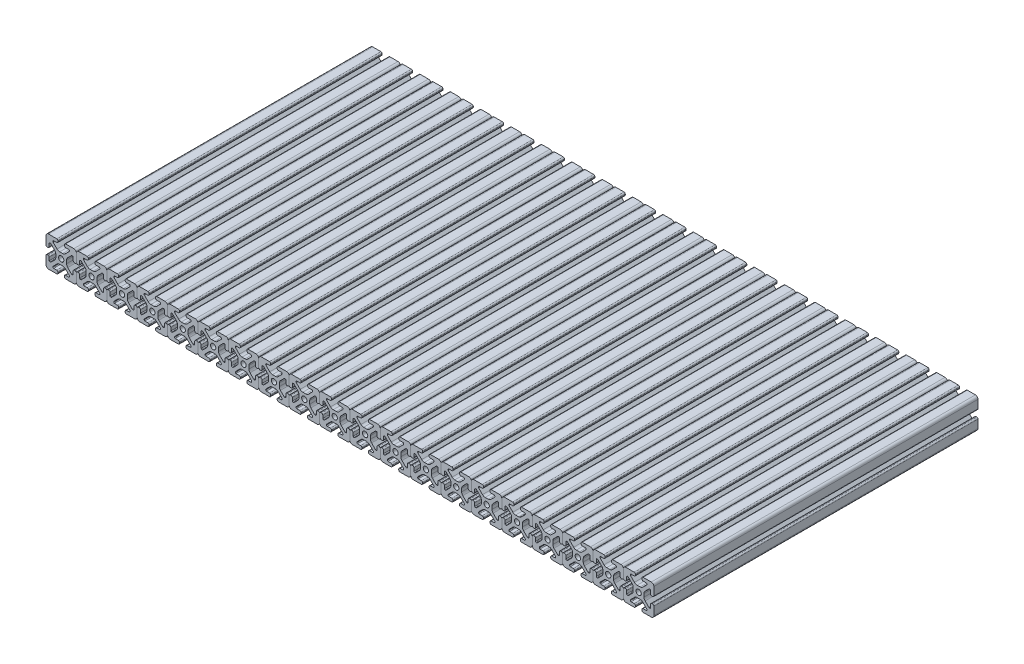
from build123d import *

# Parameters (mm, degrees)
SKETCH1_R           = 3.3274
BOSS_EXTRUDE1_DEPTH = 203.2
LPATTERN1_COUNT     = 20
LPATTERN1_PITCH     = 38.1


with BuildPart() as part:
    # Sketch1 → Boss-Extrude1 (new body, symmetric)
    with BuildSketch(Plane.XY):
        with BuildLine():
            Line((-366.014, 16.539617552), (-366.014, 17.496382454))
            ThreePointArc((-366.014, 17.496382454), (-366.469044044, 18.594955958), (-367.567617547, 19.050000004))
            Line((-367.567617547, 19.050000004), (-377.79748704, 19.050000004))
            ThreePointArc((-377.79748704, 19.050000004), (-380.07017629, 18.120192086), (-381.000000001, 15.847509297))
            Line((-381.000000001, 15.847509297), (-381.000000001, 5.617617549))
            ThreePointArc((-381.000000001, 5.617617549), (-380.544955957, 4.519044045), (-379.446382454, 4.064))
            Line((-379.446382454, 4.064), (-378.489617549, 4.064))
            ThreePointArc((-378.489617549, 4.064), (-377.391044044, 4.519044045), (-376.936, 5.617617549))
            Line((-376.936, 5.617617549), (-376.936, 9.385342517))
            ThreePointArc((-376.936, 9.385342517), (-376.671898184, 10.022940701), (-376.0343, 10.287042517))
            Line((-376.0343, 10.287042517), (-375.466042086, 10.287042517))
            ThreePointArc((-375.466042086, 10.287042517), (-375.120975923, 10.218404479), (-374.828443117, 10.022939917))
            Line((-374.828443117, 10.022939917), (-370.09758008, 5.292065242))
            ThreePointArc((-370.09758008, 5.292065242), (-369.067955877, 3.751120652), (-368.706399998, 1.933453582))
            Line((-368.706399998, 1.933453582), (-368.706399998, -1.933453584))
            ThreePointArc((-368.706399998, -1.933453584), (-369.067955877, -3.751120652), (-370.097580078, -5.292065242))
            Line((-370.097580078, -5.292065242), (-374.828443116, -10.022939917))
            ThreePointArc((-374.828443116, -10.022939917), (-375.120975922, -10.21840448), (-375.466042086, -10.287042518))
            Line((-375.466042086, -10.287042518), (-376.0343, -10.287042518))
            ThreePointArc((-376.0343, -10.287042518), (-376.671898185, -10.022940703), (-376.936, -9.385342518))
            Line((-376.936, -9.385342518), (-376.936, -5.617617549))
            ThreePointArc((-376.936, -5.617617549), (-377.391044044, -4.519044046), (-378.489617547, -4.064))
            Line((-378.489617547, -4.064), (-379.446382452, -4.064))
            ThreePointArc((-379.446382452, -4.064), (-380.544955956, -4.519044044), (-381.000000001, -5.617617547))
            Line((-381.000000001, -5.617617547), (-381.000000001, -15.84751072))
            ThreePointArc((-381.000000001, -15.84751072), (-380.070175718, -18.120192644), (-377.79748687, -19.050000001))
            Line((-377.79748687, -19.050000001), (-367.567617549, -19.050000001))
            ThreePointArc((-367.567617549, -19.050000001), (-366.469044046, -18.594955957), (-366.014, -17.496382454))
            Line((-366.014, -17.496382454), (-366.014, -16.539617549))
            ThreePointArc((-366.014, -16.539617549), (-366.469044045, -15.441044044), (-367.567617549, -14.985999999))
            Line((-367.567617549, -14.985999999), (-371.3353, -14.985999999))
            ThreePointArc((-371.3353, -14.985999999), (-371.972898185, -14.721898184), (-372.237, -14.084299999))
            Line((-372.237, -14.084299999), (-372.237, -13.552357131))
            ThreePointArc((-372.237, -13.552357131), (-372.168362387, -13.207291993), (-371.972898969, -12.914759731))
            Line((-371.972898969, -12.914759731), (-367.202158104, -8.14400713))
            ThreePointArc((-367.202158104, -8.14400713), (-365.665177371, -7.117027388), (-363.852183976, -6.7564))
            Line((-363.852183976, -6.7564), (-360.047816024, -6.7564))
            ThreePointArc((-360.047816024, -6.7564), (-358.234822628, -7.117027388), (-356.697841894, -8.144007132))
            Line((-356.697841894, -8.144007132), (-351.927101031, -12.91475973))
            ThreePointArc((-351.927101031, -12.91475973), (-351.731637613, -13.207291993), (-351.662999999, -13.552357132))
            Line((-351.662999999, -13.552357132), (-351.662999999, -14.0843))
            ThreePointArc((-351.662999999, -14.0843), (-351.927101815, -14.721898184), (-352.564699999, -14.986))
            Line((-352.564699999, -14.986), (-356.332382451, -14.986))
            ThreePointArc((-356.332382451, -14.986), (-357.430955955, -15.441044044), (-357.886, -16.539617547))
            Line((-357.886, -16.539617547), (-357.886, -17.496382452))
            ThreePointArc((-357.886, -17.496382452), (-357.430955957, -18.594955955), (-356.332382454, -19.050000001))
            Line((-356.332382454, -19.050000001), (-346.102513133, -19.050000001))
            ThreePointArc((-346.102513133, -19.050000001), (-343.829824284, -18.120192646), (-342.9, -15.847510723))
            Line((-342.9, -15.847510723), (-342.9, -5.617617549))
            ThreePointArc((-342.9, -5.617617549), (-343.355044045, -4.519044045), (-344.453617549, -4.064))
            Line((-344.453617549, -4.064), (-345.410382452, -4.064))
            ThreePointArc((-345.410382452, -4.064), (-346.508955956, -4.519044045), (-346.964000001, -5.617617549))
            Line((-346.964000001, -5.617617549), (-346.964000001, -9.385342517))
            ThreePointArc((-346.964000001, -9.385342517), (-347.228101816, -10.022940701), (-347.865700001, -10.287042517))
            Line((-347.865700001, -10.287042517), (-348.433957915, -10.287042517))
            ThreePointArc((-348.433957915, -10.287042517), (-348.779024078, -10.218404479), (-349.071556883, -10.022939917))
            Line((-349.071556883, -10.022939917), (-353.802419921, -5.292065242))
            ThreePointArc((-353.802419921, -5.292065242), (-354.832044123, -3.751120652), (-355.193600002, -1.933453583))
            Line((-355.193600002, -1.933453583), (-355.193600002, 1.933453583))
            ThreePointArc((-355.193600002, 1.933453583), (-354.832044123, 3.751120652), (-353.802419922, 5.292065242))
            Line((-353.802419922, 5.292065242), (-349.071556884, 10.022939916))
            ThreePointArc((-349.071556884, 10.022939916), (-348.779024078, 10.218404477), (-348.433957916, 10.287042515))
            Line((-348.433957916, 10.287042515), (-347.865700002, 10.287042515))
            ThreePointArc((-347.865700002, 10.287042515), (-347.228101817, 10.0229407), (-346.964000002, 9.385342515))
            Line((-346.964000002, 9.385342515), (-346.964000002, 5.617617546))
            ThreePointArc((-346.964000002, 5.617617546), (-346.508955957, 4.519044042), (-345.410382453, 4.063999997))
            Line((-345.410382453, 4.063999997), (-344.45361755, 4.063999997))
            ThreePointArc((-344.45361755, 4.063999997), (-343.355044044, 4.519044042), (-342.9, 5.617617548))
            Line((-342.9, 5.617617548), (-342.9, 15.8475093))
            ThreePointArc((-342.9, 15.8475093), (-343.829823711, 18.120192086), (-346.102512959, 19.050000004))
            Line((-346.102512959, 19.050000004), (-356.332382452, 19.050000004))
            ThreePointArc((-356.332382452, 19.050000004), (-357.430955956, 18.594955959), (-357.886000001, 17.496382454))
            Line((-357.886000001, 17.496382454), (-357.886000001, 16.539617552))
            ThreePointArc((-357.886000001, 16.539617552), (-357.430955956, 15.441044047), (-356.332382452, 14.986000002))
            Line((-356.332382452, 14.986000002), (-352.564700001, 14.986000002))
            ThreePointArc((-352.564700001, 14.986000002), (-351.927101817, 14.721898187), (-351.663000001, 14.084300002))
            Line((-351.663000001, 14.084300002), (-351.663000001, 13.552357134))
            ThreePointArc((-351.663000001, 13.552357134), (-351.731637614, 13.207291996), (-351.927101032, 12.914759734))
            Line((-351.927101032, 12.914759734), (-356.697841897, 8.144007133))
            ThreePointArc((-356.697841897, 8.144007133), (-358.23482263, 7.117027391), (-360.047816025, 6.756400003))
            Line((-360.047816025, 6.756400003), (-363.852183977, 6.756400003))
            ThreePointArc((-363.852183977, 6.756400003), (-365.665177373, 7.117027391), (-367.202158106, 8.144007134))
            Line((-367.202158106, 8.144007134), (-371.972898969, 12.914759733))
            ThreePointArc((-371.972898969, 12.914759733), (-372.168362387, 13.207291995), (-372.237000001, 13.552357134))
            Line((-372.237000001, 13.552357134), (-372.237000001, 14.084300002))
            ThreePointArc((-372.237000001, 14.084300002), (-371.972898186, 14.721898187), (-371.335300001, 14.986000002))
            Line((-371.335300001, 14.986000002), (-367.567617549, 14.986000002))
            ThreePointArc((-367.567617549, 14.986000002), (-366.469044044, 15.441044047), (-366.014, 16.539617552))
        make_face()
        with Locations((-361.95, 0)):
            Circle(SKETCH1_R, mode=Mode.SUBTRACT)
    extrude(amount=BOSS_EXTRUDE1_DEPTH, both=True)


with BuildPart() as lpattern1_1:
    # LPattern1: pattern copy
    add(part.part.moved(Location(Vector(1, 0, 0) * (1 * LPATTERN1_PITCH))))


with BuildPart() as lpattern1_2:
    # LPattern1: pattern copy
    add(part.part.moved(Location(Vector(1, 0, 0) * (2 * LPATTERN1_PITCH))))


with BuildPart() as lpattern1_3:
    # LPattern1: pattern copy
    add(part.part.moved(Location(Vector(1, 0, 0) * (3 * LPATTERN1_PITCH))))


with BuildPart() as lpattern1_4:
    # LPattern1: pattern copy
    add(part.part.moved(Location(Vector(1, 0, 0) * (4 * LPATTERN1_PITCH))))


with BuildPart() as lpattern1_5:
    # LPattern1: pattern copy
    add(part.part.moved(Location(Vector(1, 0, 0) * (5 * LPATTERN1_PITCH))))


with BuildPart() as lpattern1_6:
    # LPattern1: pattern copy
    add(part.part.moved(Location(Vector(1, 0, 0) * (6 * LPATTERN1_PITCH))))


with BuildPart() as lpattern1_7:
    # LPattern1: pattern copy
    add(part.part.moved(Location(Vector(1, 0, 0) * (7 * LPATTERN1_PITCH))))


with BuildPart() as lpattern1_8:
    # LPattern1: pattern copy
    add(part.part.moved(Location(Vector(1, 0, 0) * (8 * LPATTERN1_PITCH))))


with BuildPart() as lpattern1_9:
    # LPattern1: pattern copy
    add(part.part.moved(Location(Vector(1, 0, 0) * (9 * LPATTERN1_PITCH))))


with BuildPart() as lpattern1_10:
    # LPattern1: pattern copy
    add(part.part.moved(Location(Vector(1, 0, 0) * (10 * LPATTERN1_PITCH))))


with BuildPart() as lpattern1_11:
    # LPattern1: pattern copy
    add(part.part.moved(Location(Vector(1, 0, 0) * (11 * LPATTERN1_PITCH))))


with BuildPart() as lpattern1_12:
    # LPattern1: pattern copy
    add(part.part.moved(Location(Vector(1, 0, 0) * (12 * LPATTERN1_PITCH))))


with BuildPart() as lpattern1_13:
    # LPattern1: pattern copy
    add(part.part.moved(Location(Vector(1, 0, 0) * (13 * LPATTERN1_PITCH))))


with BuildPart() as lpattern1_14:
    # LPattern1: pattern copy
    add(part.part.moved(Location(Vector(1, 0, 0) * (14 * LPATTERN1_PITCH))))


with BuildPart() as lpattern1_15:
    # LPattern1: pattern copy
    add(part.part.moved(Location(Vector(1, 0, 0) * (15 * LPATTERN1_PITCH))))


with BuildPart() as lpattern1_16:
    # LPattern1: pattern copy
    add(part.part.moved(Location(Vector(1, 0, 0) * (16 * LPATTERN1_PITCH))))


with BuildPart() as lpattern1_17:
    # LPattern1: pattern copy
    add(part.part.moved(Location(Vector(1, 0, 0) * (17 * LPATTERN1_PITCH))))


with BuildPart() as lpattern1_18:
    # LPattern1: pattern copy
    add(part.part.moved(Location(Vector(1, 0, 0) * (18 * LPATTERN1_PITCH))))


with BuildPart() as lpattern1_19:
    # LPattern1: pattern copy
    add(part.part.moved(Location(Vector(1, 0, 0) * (19 * LPATTERN1_PITCH))))


solid = Compound([part.part, lpattern1_1.part, lpattern1_2.part, lpattern1_3.part, lpattern1_4.part, lpattern1_5.part, lpattern1_6.part, lpattern1_7.part, lpattern1_8.part, lpattern1_9.part, lpattern1_10.part, lpattern1_11.part, lpattern1_12.part, lpattern1_13.part, lpattern1_14.part, lpattern1_15.part, lpattern1_16.part, lpattern1_17.part, lpattern1_18.part, lpattern1_19.part])
